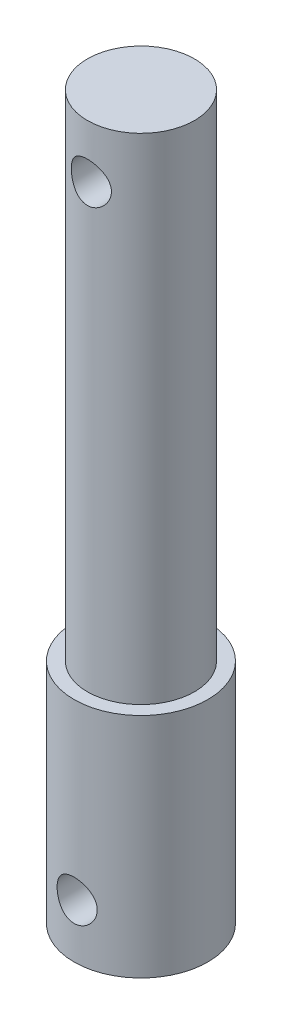
from build123d import *

# Parameters (mm, degrees)
SKETCH1_R               = 5
BOSS_EXTRUDE1_DEPTH     = 17
SKETCH1_3_R             = 4
BOSS_EXTRUDE2_DEPTH     = 54
CUT_EXTRUDE1_DEPTH      = 55.460995217
CUT_EXTRUDE1_DEPTH_BACK = 55.460995217
SKETCH2_R               = 1.5


with BuildPart() as part:
    # Sketch1 → Boss-Extrude1 (new body)
    with BuildSketch(Plane(origin=(0, 0, 0), x_dir=(1, 0, 0), z_dir=(0, 1, 0))):
        Circle(SKETCH1_R)
    extrude(amount=BOSS_EXTRUDE1_DEPTH)

    # Sketch1_3 → Boss-Extrude2 (add)
    with BuildSketch(Plane(origin=(0, 0, 0), x_dir=(1, 0, 0), z_dir=(0, 1, 0))):
        Circle(SKETCH1_3_R)
    extrude(amount=BOSS_EXTRUDE2_DEPTH)

    # Sketch2 → Cut-Extrude1 (cut, two sides: drawn at the far end of the back side and taken through both)
    with BuildSketch(Plane.XY.offset(-CUT_EXTRUDE1_DEPTH_BACK)):
        with Locations((0, 50)):
            Circle(SKETCH2_R)
        with Locations((0, 4)):
            Circle(SKETCH2_R)
    extrude(amount=CUT_EXTRUDE1_DEPTH + CUT_EXTRUDE1_DEPTH_BACK, mode=Mode.SUBTRACT)


solid = part.part
